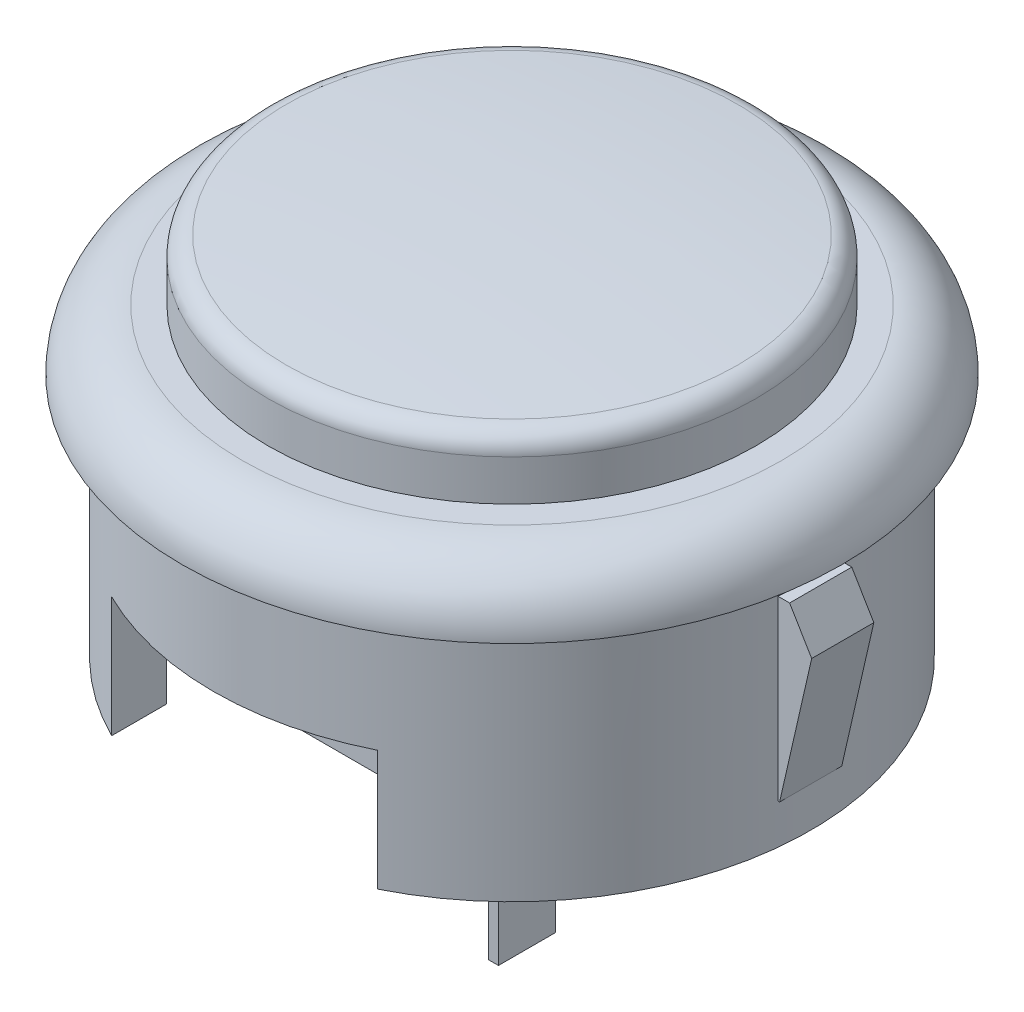
from build123d import *

# Parameters (mm, degrees)
SKETCH2_W               = 13.25
SKETCH2_H               = 6
CUT_EXTRUDE1_DEPTH      = 17.45
CUT_EXTRUDE1_DEPTH_BACK = 17.45
BOSS_EXTRUDE1_DEPTH     = 1.55
SKETCH4_W               = 12
SKETCH4_H               = 12.75
BOSS_EXTRUDE2_DEPTH     = 8
SKETCH5_W               = 0.5
SKETCH5_H               = 2.85
BOSS_EXTRUDE3_DEPTH     = 8.25


with BuildPart() as part:
    # Sketch1 → Revolve1 (revolve)
    with BuildSketch(Plane.XY):
        with BuildLine():
            Line((16.45, 0), (14.9, 0))
            Line((14.9, 0), (14.9, -12.25))
            Line((14.9, -12.25), (12.5, -12.25))
            Line((12.5, -12.25), (12.5, -6.25))
            Line((12.5, -6.25), (0, -6.25))
            Line((0, -6.25), (0, 6.55))
            ThreePointArc((0, 6.55), (5.638841208, 6.421540892), (11.26598272, 6.0364301))
            ThreePointArc((11.26598272, 6.0364301), (11.913573869, 5.714750188), (12.175, 5.040577629))
            Line((12.175, 5.040577629), (12.175, 3))
            Line((12.175, 3), (13.45, 3))
            ThreePointArc((13.45, 3), (15.571320344, 2.121320344), (16.45, 0))
        make_face()
    revolve(axis=Axis((0, 7.971043953, 0), (0, -1, 0)))

    # Sketch2 → Cut-Extrude1 (cut, two sides)
    with BuildSketch(Plane.XY) as cut_extrude1_sk:
        with Locations((0, -9.25)):
            Rectangle(SKETCH2_W, SKETCH2_H)
    extrude(amount=CUT_EXTRUDE1_DEPTH, mode=Mode.SUBTRACT)
    extrude(cut_extrude1_sk.sketch, amount=-CUT_EXTRUDE1_DEPTH_BACK, mode=Mode.SUBTRACT)

    # Sketch3 → Boss-Extrude1 (add, symmetric)
    with BuildSketch(Plane.XY):
        Polygon((14.9, -10.25), (16.5, -3.25), (15.4, -1.4), (13.9, -1.4), (13.9, -10.25), align=None)
    boss_extrude1 = extrude(amount=BOSS_EXTRUDE1_DEPTH, both=True)

    # Mirror1: Boss-Extrude1 across plane
    add(boss_extrude1.mirror(Plane(origin=(0, 0, 0), x_dir=(0, 0, 1), z_dir=(1, 0, 0))))

    # Sketch4 → Boss-Extrude2 (add)
    with BuildSketch(Plane.XZ.offset(6.25)):
        Rectangle(SKETCH4_W, SKETCH4_H)
    extrude(amount=BOSS_EXTRUDE2_DEPTH)

    # Sketch5 → Boss-Extrude3 (add)
    with BuildSketch(Plane.XZ.offset(14.25)):
        with Locations((2.45, 1.95)):
            Rectangle(SKETCH5_W, SKETCH5_H)
        with Locations((-2.45, -1.95)):
            Rectangle(SKETCH5_W, SKETCH5_H)
    extrude(amount=BOSS_EXTRUDE3_DEPTH)


solid = part.part
